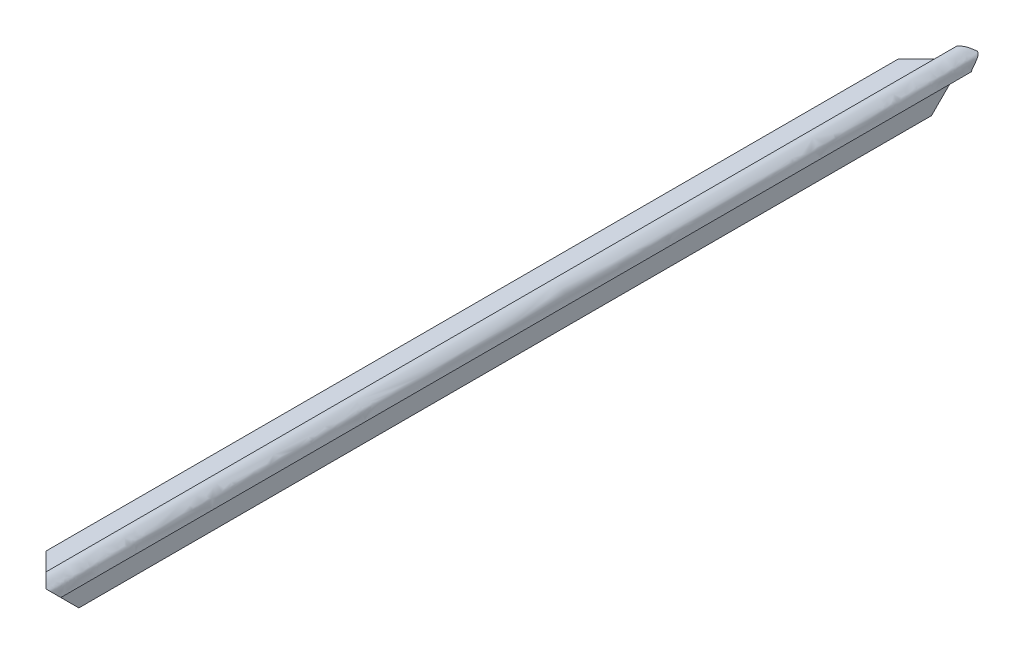
from build123d import *

# Parameters (mm, degrees)
SKETCH7_W               = 7.9375
SKETCH7_H               = 3.000000096
BOSS_EXTRUDE2_DEPTH     = 130.175
SKETCH8_W               = 3.000000096
SKETCH8_H               = 7.9375
BOSS_EXTRUDE3_DEPTH     = 130.175
BOSS_EXTRUDE4_DEPTH     = 130.175
CUT_EXTRUDE4_DEPTH      = 132.01559704
CUT_EXTRUDE4_DEPTH_BACK = 132.01559704
CUT_EXTRUDE5_DEPTH      = 130.351482615
CUT_EXTRUDE5_DEPTH_BACK = 130.351482615


with BuildPart() as part:
    # Sketch7 → Boss-Extrude2 (new, symmetric)
    with BuildSketch(Plane.XY):
        with Locations((-6.50875, -3.000000096)):
            Rectangle(SKETCH7_W, SKETCH7_H)
    extrude(amount=BOSS_EXTRUDE2_DEPTH, both=True)

    # Sketch8 → Boss-Extrude3 (add, symmetric)
    with BuildSketch(Plane.XY):
        with Locations((-3.000000096, -6.50875)):
            Rectangle(SKETCH8_W, SKETCH8_H)
    extrude(amount=BOSS_EXTRUDE3_DEPTH, both=True)

    # Sketch11 → Boss-Extrude4 (add, symmetric)
    with BuildSketch(Plane.XY):
        with BuildLine():
            Line((-2.54, 1.500000048), (-2.54, -1.500000048))
            Line((-2.54, -1.500000048), (-10.4775, -1.500000048))
            Line((-10.4775, -1.500000048), (-10.4775, -4.500000144))
            Line((-10.4775, -4.500000144), (-6.745064174, -4.500000144))
            Line((-6.745064174, -4.500000144), (-4.500000144, -6.745064174))
            Line((-4.500000144, -6.745064174), (-4.500000144, -10.4775))
            Line((-4.500000144, -10.4775), (-1.500000048, -10.4775))
            Line((-1.500000048, -10.4775), (-1.500000048, -2.54))
            Line((-1.500000048, -2.54), (1.500000048, -2.54))
            add(Edge.make_bspline(
                [(-2.54, 1.500000048), (-1.295649087, 1.635512934), (-0.042467258, 0.473225958), (1.297713539, -0.292226779), (1.263724591, -2.340394541), (1.500000048, -2.54)],
                knots=[0, 0, 0, 0, 0.496686972, 0.741346965, 0.899739924, 0.899739924, 0.899739924, 0.899739924], degree=3))
        make_face()
    extrude(amount=BOSS_EXTRUDE4_DEPTH, both=True)

    # Sketch14 → Cut-Extrude4 (cut, two sides: drawn at the far end of the back side and taken through both)
    with BuildSketch(Plane(origin=(0, 0, 0), x_dir=(1, 0, 0), z_dir=(0, 1, 0)).offset(-CUT_EXTRUDE4_DEPTH_BACK)):
        Polygon((-10.4775, -116.5225), (-10.4775, -137.4775), (10.4775, -137.4775), align=None)
        Polygon((-10.4775, 116.5225), (10.4775, 137.4775), (-10.4775, 137.4775), align=None)
    extrude(amount=CUT_EXTRUDE4_DEPTH + CUT_EXTRUDE4_DEPTH_BACK, mode=Mode.SUBTRACT)

    # Sketch17 → Cut-Extrude5 (cut, two sides: drawn at the far end of the back side and taken through both)
    with BuildSketch(Plane(origin=(0, 0, 0), x_dir=(0, -1, 0), z_dir=(-1, 0, 0)).offset(-CUT_EXTRUDE5_DEPTH_BACK)):
        Polygon((10.4775, 137.4775), (10.4775, 116.5225), (-10.4775, 137.4775), align=None)
        Polygon((10.4775, -116.5225), (-10.4775, -137.4775), (10.4775, -137.4775), align=None)
    extrude(amount=CUT_EXTRUDE5_DEPTH + CUT_EXTRUDE5_DEPTH_BACK, mode=Mode.SUBTRACT)


solid = part.part
